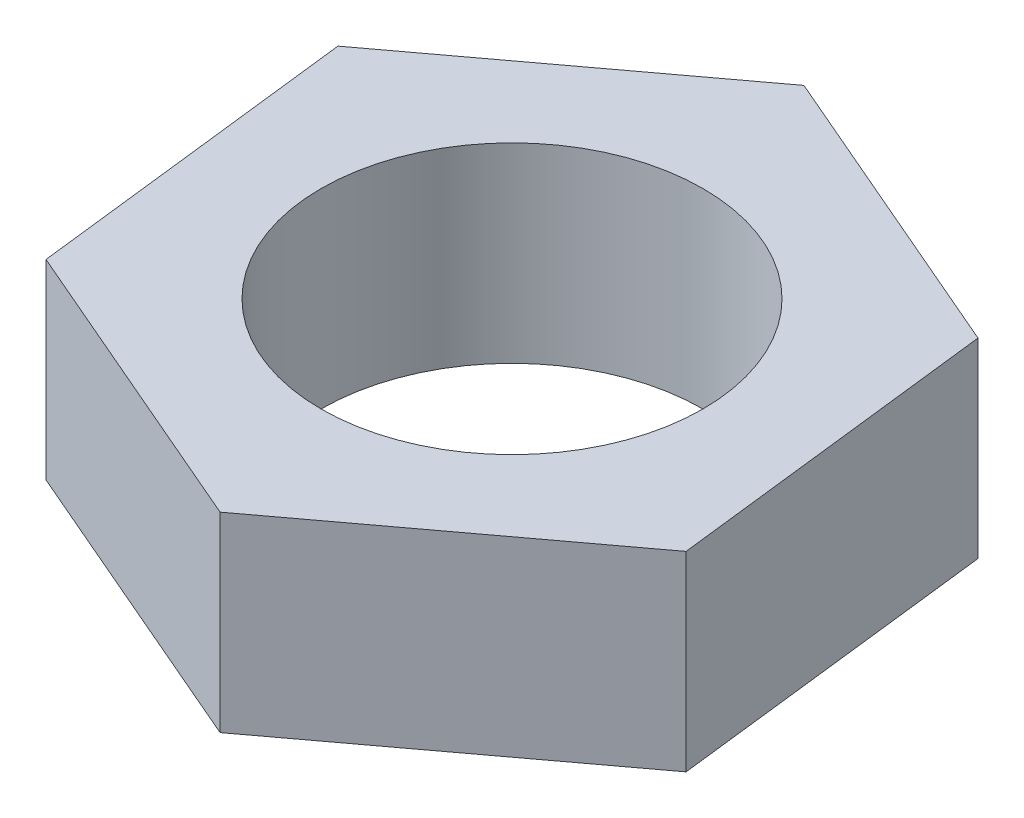
from build123d import *

# Parameters (mm, degrees)
BOSS_EXTRU_1_DEPTH      = 10
ESQUISSE2_R             = 10
ENL_V_MAT_EXTRU_1_DEPTH = 10


with BuildPart() as part:
    # Esquisse1 → Boss.-Extru.1 (new body)
    with BuildSketch(Plane(origin=(0, 0, 0), x_dir=(1, 0, 0), z_dir=(0, 1, 0))):
        Polygon((-16.016238375, 6.900077539), (-13.983761625, -10.420430537), (2.032476751, -17.320508076), (16.016238375, -6.900077539), (13.983761625, 10.420430537), (-2.032476751, 17.320508076), align=None)
    extrude(amount=BOSS_EXTRU_1_DEPTH)

    # Esquisse2 → Enlèv. mat.-Extru.1 (cut)
    with BuildSketch(Plane(origin=(0, 10, 0), x_dir=(1, 0, 0), z_dir=(0, 1, 0))):
        Circle(ESQUISSE2_R)
    extrude(amount=-ENL_V_MAT_EXTRU_1_DEPTH, mode=Mode.SUBTRACT)


solid = part.part
